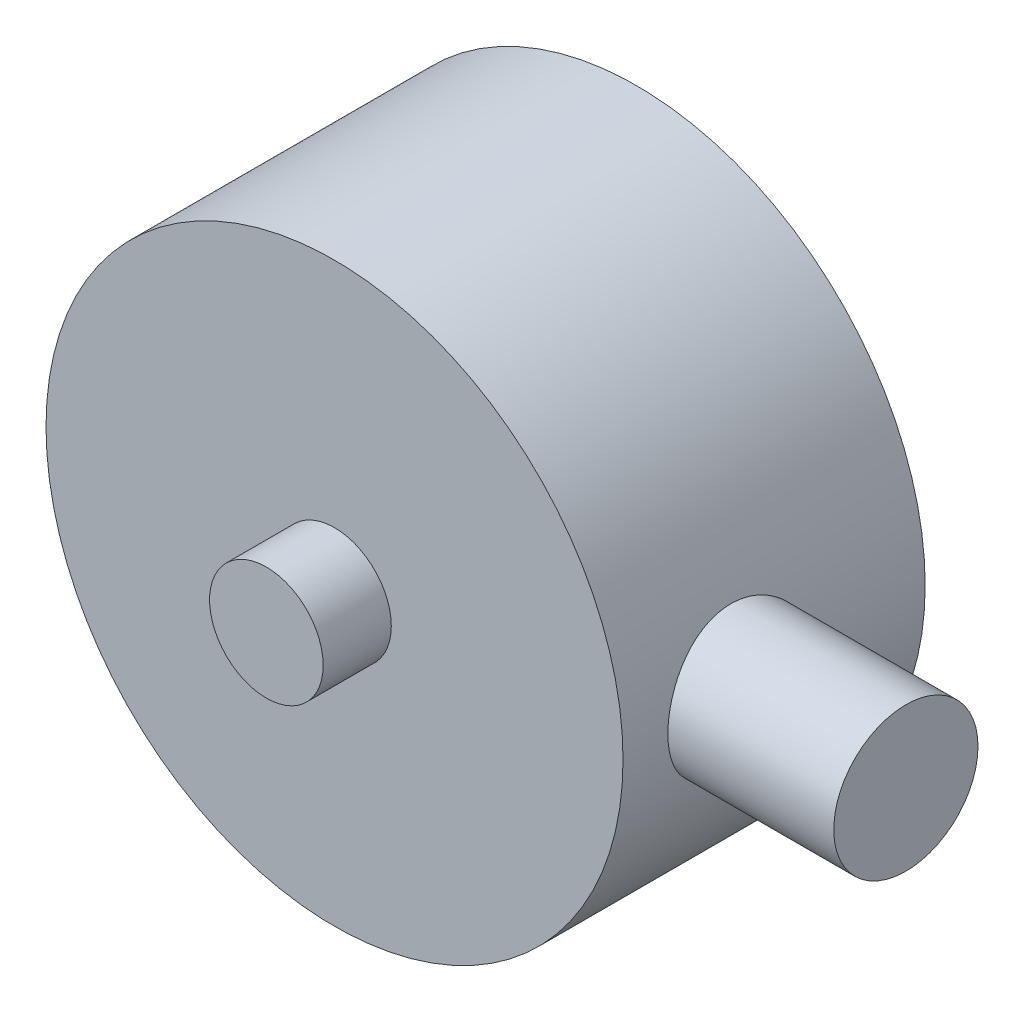
from build123d import *

# Parameters (mm, degrees)
SKETCH1_R                = 12.7
BOSS_EXTRUDE1_DEPTH      = 13.3
BOSS_EXTRUDE2_DEPTH      = 16.3
BOSS_EXTRUDE2_DEPTH_BACK = 6.35
SKETCH1_3_R              = 2.5
SKETCH2_R                = 3.175
BOSS_EXTRUDE3_DEPTH      = 20


with BuildPart() as part:
    # Sketch1 → Boss-Extrude1 (new body)
    with BuildSketch(Plane.XY):
        Circle(SKETCH1_R)
    extrude(amount=BOSS_EXTRUDE1_DEPTH)

    # Sketch1_3 → Boss-Extrude2 (add, two sides: drawn at the far end of the back side and taken through both)
    with BuildSketch(Plane.XY.offset(-BOSS_EXTRUDE2_DEPTH_BACK)):
        Circle(SKETCH1_3_R)
    extrude(amount=BOSS_EXTRUDE2_DEPTH + BOSS_EXTRUDE2_DEPTH_BACK)

    # Sketch2 → Boss-Extrude3 (add)
    with BuildSketch(Plane(origin=(0, 0, 0), x_dir=(0, 0, -1), z_dir=(1, 0, 0))):
        with Locations((-8.15, 0)):
            Circle(SKETCH2_R)
    extrude(amount=BOSS_EXTRUDE3_DEPTH)


solid = part.part
